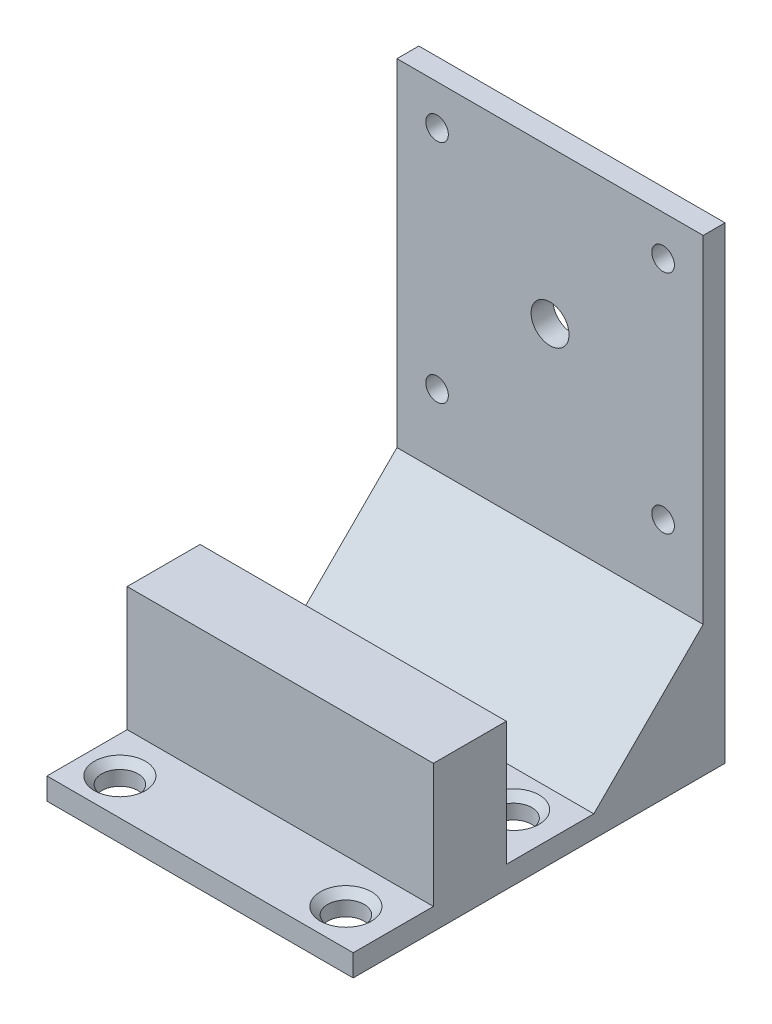
from build123d import *

# Parameters (mm, degrees)
ESQUISSE1_W             = 42
ESQUISSE1_H             = 42
ESQUISSE1_R             = 2.6
ESQUISSE1_R_2           = 1.55
ESQUISSE1_H_2           = 22.2
BOSS_EXTRU_1_DEPTH      = 3
ESQUISSE2_W             = 42
ESQUISSE2_H             = 3
BOSS_EXTRU_2_DEPTH      = 48
BOSS_EXTRU_3_DEPTH      = 42
ENL_V_MAT_EXTRU_4_REACH = 5
ESQUISSE4_R             = 2.5
CHANFREIN1_SIZE         = 1
ESQUISSE5_W             = 42
ESQUISSE5_H             = 10
BOSS_EXTRU_4_DEPTH      = 17


with BuildPart() as part:
    # Esquisse1 → Boss.-Extru.1 (new body)
    with BuildSketch(Plane.XY):
        with Locations((21, 21)):
            Rectangle(ESQUISSE1_W, ESQUISSE1_H)
        with Locations((21, 21)):
            Circle(ESQUISSE1_R, mode=Mode.SUBTRACT)
        with Locations((5.5, 36.5)):
            Circle(ESQUISSE1_R_2, mode=Mode.SUBTRACT)
        with Locations((36.5, 36.5)):
            Circle(ESQUISSE1_R_2, mode=Mode.SUBTRACT)
        with Locations((36.5, 5.5)):
            Circle(ESQUISSE1_R_2, mode=Mode.SUBTRACT)
        with Locations((5.5, 5.5)):
            Circle(ESQUISSE1_R_2, mode=Mode.SUBTRACT)
        with Locations((21, -11.1)):
            Rectangle(ESQUISSE1_W, ESQUISSE1_H_2)
    extrude(amount=BOSS_EXTRU_1_DEPTH)

    # Esquisse2 → Boss.-Extru.2 (add)
    with BuildSketch(Plane.XY.offset(3)):
        with Locations((21, -20.7)):
            Rectangle(ESQUISSE2_W, ESQUISSE2_H)
    extrude(amount=BOSS_EXTRU_2_DEPTH)

    # Esquisse3 → Boss.-Extru.3 (add)
    with BuildSketch(Plane(origin=(42, 0, 0), x_dir=(0, 0, -1), z_dir=(1, 0, 0))):
        Polygon((-3, -4.2), (-18, -19.2), (-3, -19.2), align=None)
    extrude(amount=-BOSS_EXTRU_3_DEPTH)

    # Esquisse4 → Enlèv. mat.-Extru.4 (cut, up to next)
    with BuildSketch(Plane(origin=(0, -19.2, 0), x_dir=(1, 0, 0), z_dir=(0, 1, 0)), mode=Mode.PRIVATE) as enl_v_mat_extru_4_sk1:
        with Locations((5, -23)):
            Circle(ESQUISSE4_R)
    enl_v_mat_extru_4_tool1 = extrude(enl_v_mat_extru_4_sk1.sketch, amount=-ENL_V_MAT_EXTRU_4_REACH, mode=Mode.PRIVATE) & part.part
    add(enl_v_mat_extru_4_tool1.solids().sort_by_distance((5, -19.2, 23))[0], mode=Mode.SUBTRACT)
    # Esquisse4 → Enlèv. mat.-Extru.4 (cut, up to next)
    with BuildSketch(Plane(origin=(0, -19.2, 0), x_dir=(1, 0, 0), z_dir=(0, 1, 0)), mode=Mode.PRIVATE) as enl_v_mat_extru_4_sk2:
        with Locations((36, -23)):
            Circle(ESQUISSE4_R)
    enl_v_mat_extru_4_tool2 = extrude(enl_v_mat_extru_4_sk2.sketch, amount=-ENL_V_MAT_EXTRU_4_REACH, mode=Mode.PRIVATE) & part.part
    add(enl_v_mat_extru_4_tool2.solids().sort_by_distance((36, -19.2, 23))[0], mode=Mode.SUBTRACT)
    # Esquisse4 → Enlèv. mat.-Extru.4 (cut, up to next)
    with BuildSketch(Plane(origin=(0, -19.2, 0), x_dir=(1, 0, 0), z_dir=(0, 1, 0)), mode=Mode.PRIVATE) as enl_v_mat_extru_4_sk3:
        with Locations((36, -46)):
            Circle(ESQUISSE4_R)
    enl_v_mat_extru_4_tool3 = extrude(enl_v_mat_extru_4_sk3.sketch, amount=-ENL_V_MAT_EXTRU_4_REACH, mode=Mode.PRIVATE) & part.part
    add(enl_v_mat_extru_4_tool3.solids().sort_by_distance((36, -19.2, 46))[0], mode=Mode.SUBTRACT)
    # Esquisse4 → Enlèv. mat.-Extru.4 (cut, up to next)
    with BuildSketch(Plane(origin=(0, -19.2, 0), x_dir=(1, 0, 0), z_dir=(0, 1, 0)), mode=Mode.PRIVATE) as enl_v_mat_extru_4_sk4:
        with Locations((5, -46)):
            Circle(ESQUISSE4_R)
    enl_v_mat_extru_4_tool4 = extrude(enl_v_mat_extru_4_sk4.sketch, amount=-ENL_V_MAT_EXTRU_4_REACH, mode=Mode.PRIVATE) & part.part
    add(enl_v_mat_extru_4_tool4.solids().sort_by_distance((5, -19.2, 46))[0], mode=Mode.SUBTRACT)

    # Chanfrein1
    chanfrein1_edges = [part.edges().sort_by_distance(p)[0] for p in [
        (2.5, -19.2, 46),
        (33.5, -19.2, 46),
        (33.5, -19.2, 23),
        (2.5, -19.2, 23),
    ]]
    chamfer(chanfrein1_edges, length=CHANFREIN1_SIZE)

    # Esquisse5 → Boss.-Extru.4 (add)
    with BuildSketch(Plane(origin=(0, -19.2, 0), x_dir=(1, 0, 0), z_dir=(0, 1, 0))):
        with Locations((21, -35)):
            Rectangle(ESQUISSE5_W, ESQUISSE5_H)
    extrude(amount=BOSS_EXTRU_4_DEPTH)


solid = part.part
